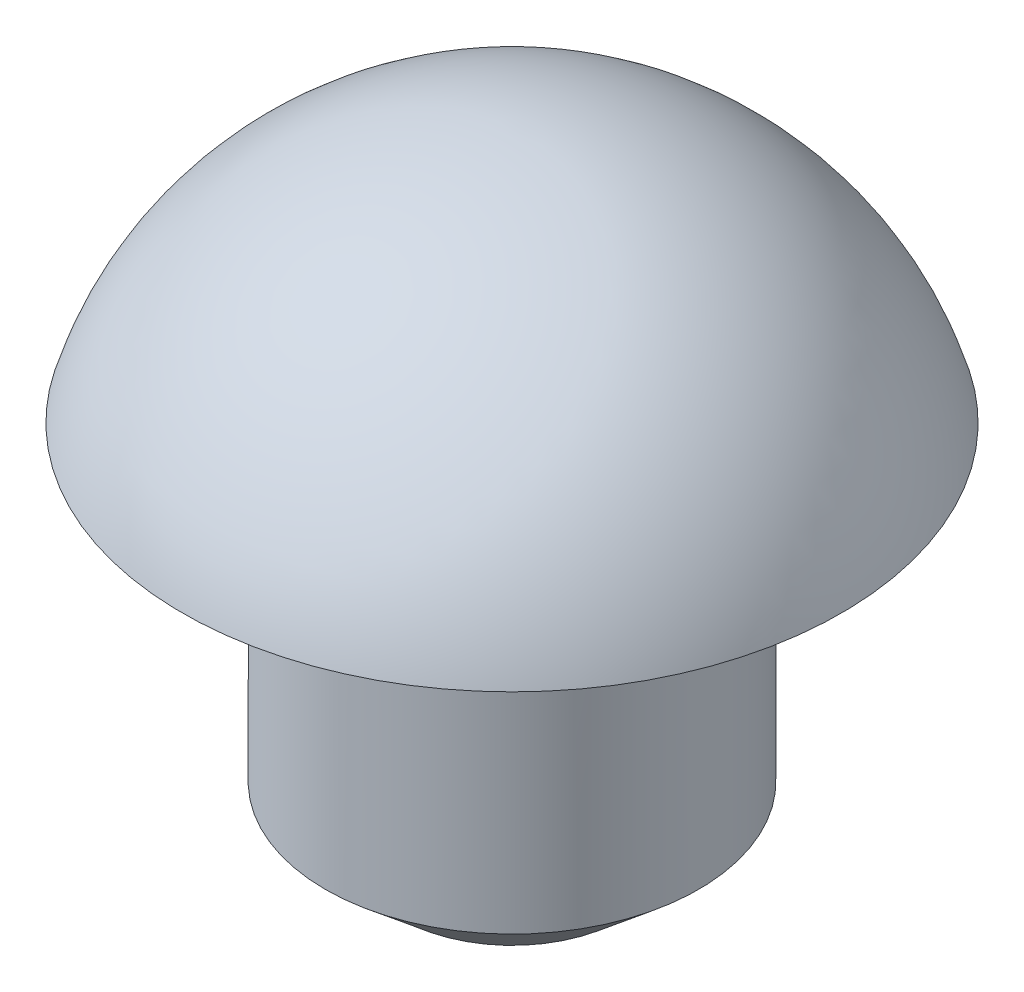
from build123d import *

# Parameters (mm, degrees)
SKIZZE1_W   = 2.65
SKIZZE1_H   = 5
SKIZZE2_W   = 1.15
SKIZZE2_H   = 3
FASE1_SIZE  = 0.5
FASE1_SIZE2 = 0.595876796


with BuildPart() as part:
    # Skizze1 → Rotation1 (revolve)
    with BuildSketch(Plane.XY):
        with Locations((-1.325, 0)):
            Rectangle(SKIZZE1_W, SKIZZE1_H)
    revolve(axis=Axis((0, -7.45771041, 0), (0, 1, 0)))

    # Skizze2 → Schnitt-Rotation1 (revolve, cut)
    with BuildSketch(Plane.XY):
        with Locations((-2.075, -1)):
            Rectangle(SKIZZE2_W, SKIZZE2_H)
    revolve(axis=Axis((0, -7.45771041, 0), (0, 1, 0)), mode=Mode.SUBTRACT)

    # Skizze3 → Schnitt-Rotation2 (revolve, cut)
    with BuildSketch(Plane.XY):
        with BuildLine():
            Line((-2.65, 0.5), (-4.39181551, 0.5))
            Line((-4.39181551, 0.5), (-4.39181551, 3.889875423))
            Line((-4.39181551, 3.889875423), (0, 3.889875423))
            Line((0, 3.889875423), (0, 2.5))
            ThreePointArc((0, 2.5), (-1.66000753, 1.943884977), (-2.65, 0.5))
        make_face()
    revolve(axis=Axis((0, -7.45771041, 0), (0, 1, 0)), mode=Mode.SUBTRACT)

    # Fase1
    fase1_edges = [part.edges().sort_by_distance(p)[0] for p in [
        (1.5, -2.5, 0),
    ]]
    fase1_side = [part.faces().sort_by_distance(p)[0] for p in [
        (1.5, -1, 0),
    ]]
    chamfer(fase1_edges, length=FASE1_SIZE, length2=FASE1_SIZE2, reference=fase1_side[0])


solid = part.part
